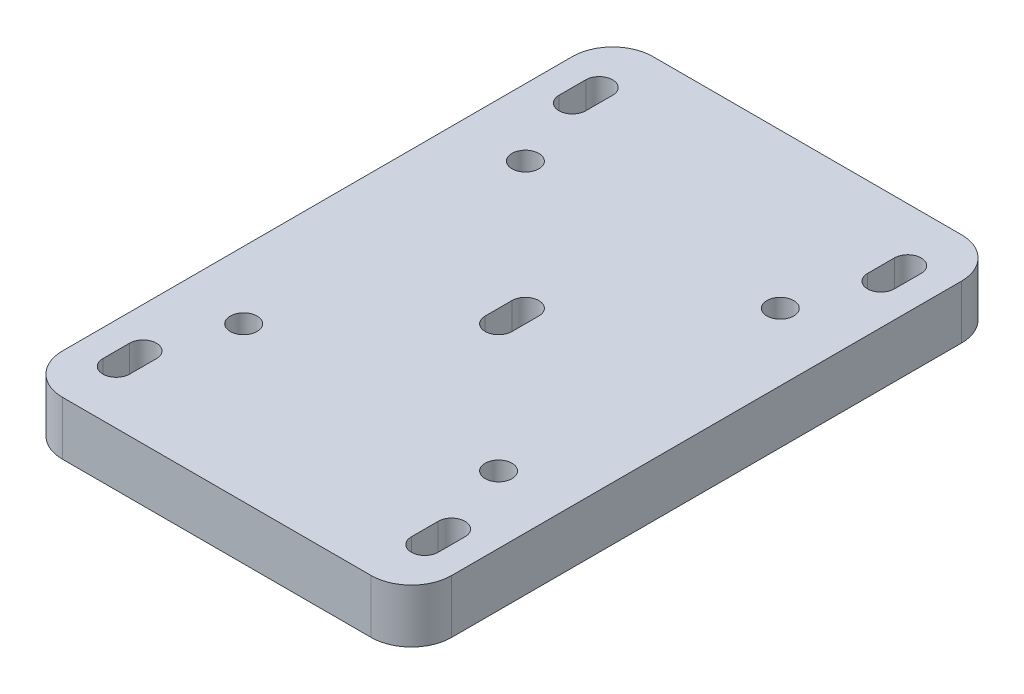
from build123d import *

# Parameters (mm, degrees)
SKETCH1_W                   = 92.075
SKETCH1_H                   = 139.7
BOSS_EXTRUDE1_DEPTH         = 12.7
F_1_4_0_25_DIAMETER_HOLE1_D = 6.35
CUT_EXTRUDE1_DEPTH          = 12.7
FILLET1_R                   = 9.525


with BuildPart() as part:
    # Sketch1 → Boss-Extrude1 (new body)
    with BuildSketch(Plane(origin=(0, 0, 0), x_dir=(1, 0, 0), z_dir=(0, 1, 0))):
        with Locations((46.0375, 69.85)):
            Rectangle(SKETCH1_W, SKETCH1_H)
    extrude(amount=BOSS_EXTRUDE1_DEPTH)

    # 1/4 (0.25) Diameter Hole1 (through all)
    with Locations(Plane(origin=(0, 12.7, 0), x_dir=(1, 0, 0), z_dir=(0, 1, 0))):
        with Locations((76.2, 36.5125), (46.0375, 69.85), (76.2, 103.1875), (15.875, 36.5125), (15.875, 103.1875)):
            Hole(F_1_4_0_25_DIAMETER_HOLE1_D / 2)

    # Sketch7 → Cut-Extrude1 (cut)
    with BuildSketch(Plane(origin=(0, 12.7, 0), x_dir=(1, 0, 0), z_dir=(0, 1, 0))):
        with BuildLine():
            Line((12.7, 127), (12.7, 120.65))
            ThreePointArc((12.7, 120.65), (9.525, 117.475), (6.35, 120.65))
            Line((6.35, 120.65), (6.35, 127))
            ThreePointArc((6.35, 127), (9.525, 130.175), (12.7, 127))
        make_face()
    cut_extrude1 = extrude(amount=-CUT_EXTRUDE1_DEPTH, mode=Mode.SUBTRACT)

    # Sketch-Pattern1: Cut-Extrude1 at 4 more places
    with Locations((36.5125, 0, 53.975), (73.025, 0, 0), (73.025, 0, 107.95), (0, 0, 107.95)):
        add(cut_extrude1, mode=Mode.SUBTRACT)

    # Fillet1
    fillet1_edges = [part.edges().sort_by_distance(p)[0] for p in [
        (0, 6.35, -139.7),
        (92.075, 6.35, -139.7),
        (92.075, 6.35, 0),
        (0, 6.35, 0),
    ]]
    fillet(fillet1_edges, radius=FILLET1_R)


solid = part.part
